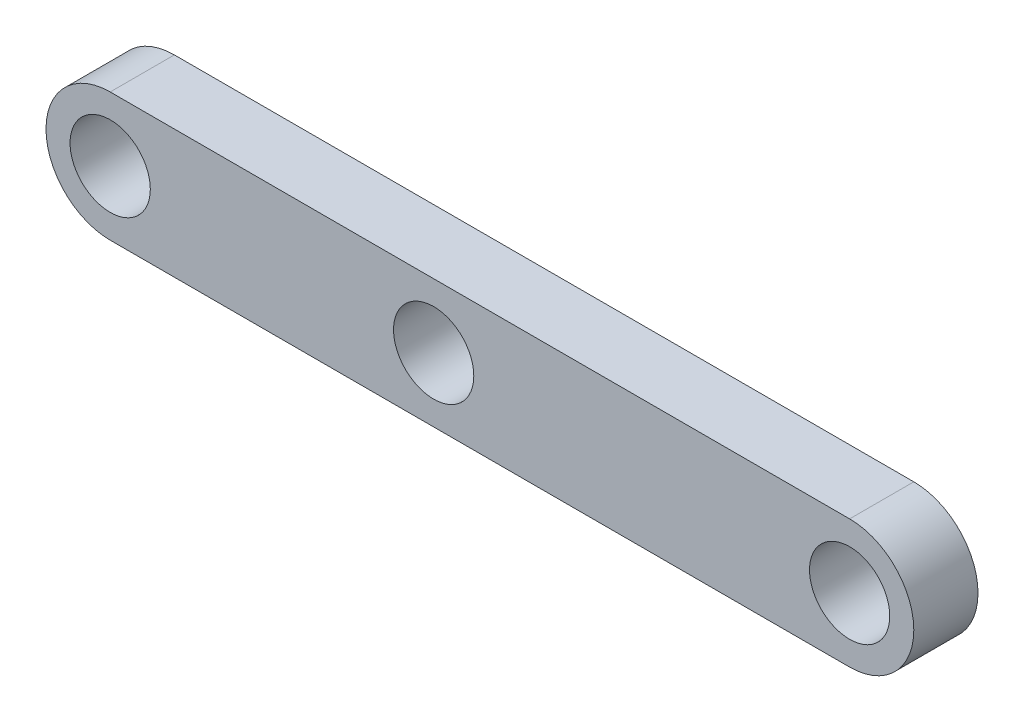
from build123d import *

# Parameters (mm, degrees)
SKETCH1_R           = 1.984375
BOSS_EXTRUDE1_DEPTH = 3.175


with BuildPart() as part:
    # Sketch1 → Boss-Extrude1 (new body)
    with BuildSketch(Plane.XY):
        with BuildLine():
            Line((-8, -3.175), (28.575, -3.175))
            ThreePointArc((28.575, -3.175), (31.75, 0), (28.575, 3.175))
            Line((28.575, 3.175), (-8, 3.175))
            ThreePointArc((-8, 3.175), (-11.175, 0), (-8, -3.175))
        make_face()
        with Locations((8, 0)):
            Circle(SKETCH1_R, mode=Mode.SUBTRACT)
        with Locations((-8, 0)):
            Circle(SKETCH1_R, mode=Mode.SUBTRACT)
        with Locations((28.575, 0)):
            Circle(SKETCH1_R, mode=Mode.SUBTRACT)
    extrude(amount=BOSS_EXTRUDE1_DEPTH)


solid = part.part
